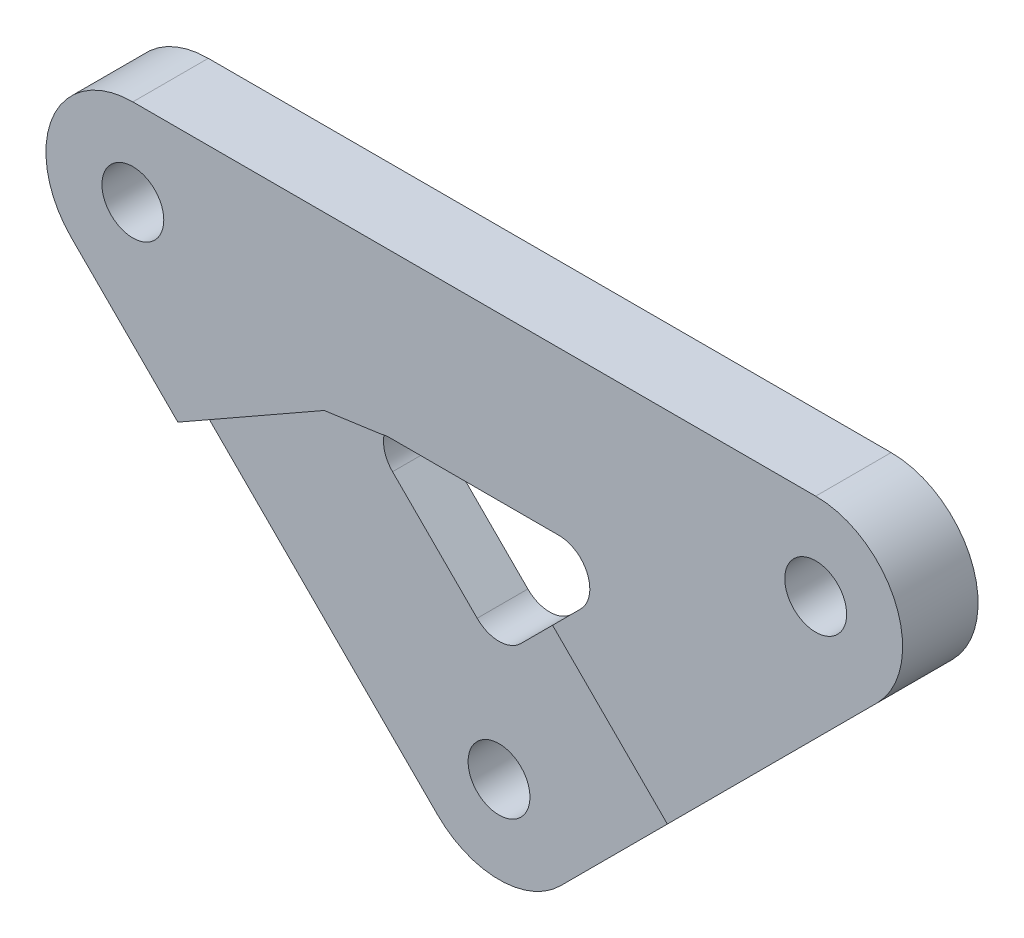
from build123d import *

# Parameters (mm, degrees)
SCHIZZO1_R                   = 2.05
ESTRUSIONE_ESTRUSIONE1_DEPTH = 5
CUT_EXTRUDE2_DEPTH           = 1.64


with BuildPart() as part:
    # Schizzo1 → Estrusione-Estrusione1 (new body)
    with BuildSketch(Plane.XY):
        with BuildLine():
            Line((22.627416998, 28.387976608), (-22.627416998, 28.387976608))
            ThreePointArc((-22.627416998, 28.387976608), (-27.949480117, 24.831887722), (-26.700747761, 18.554086235))
            Line((-26.700747761, 18.554086235), (-4.073330763, -4.073330763))
            ThreePointArc((-4.073330763, -4.073330763), (0, -5.76055961), (4.073330763, -4.073330763))
            Line((4.073330763, -4.073330763), (26.700747761, 18.554086235))
            ThreePointArc((26.700747761, 18.554086235), (27.949480117, 24.831887722), (22.627416998, 28.387976608))
        make_face()
        Circle(SCHIZZO1_R, mode=Mode.SUBTRACT)
        with Locations((22.627416998, 22.627416998)):
            Circle(SCHIZZO1_R, mode=Mode.SUBTRACT)
        with Locations((-22.627416998, 22.627416998)):
            Circle(SCHIZZO1_R, mode=Mode.SUBTRACT)
        with BuildLine():
            Line((5.607211383, 17.627416998), (-5.607211383, 17.627416998))
            ThreePointArc((-5.607211383, 17.627416998), (-7.501164425, 16.361918034), (-7.056780285, 14.127848097))
            Line((-7.056780285, 14.127848097), (-1.449568901, 8.520636713))
            ThreePointArc((-1.449568901, 8.520636713), (0, 7.920205615), (1.449568901, 8.520636713))
            Line((1.449568901, 8.520636713), (7.056780285, 14.127848097))
            ThreePointArc((7.056780285, 14.127848097), (7.501164425, 16.361918034), (5.607211383, 17.627416998))
        make_face(mode=Mode.SUBTRACT)
    extrude(amount=ESTRUSIONE_ESTRUSIONE1_DEPTH)

    # Sketch2 → Cut-Extrude2 (cut)
    with BuildSketch(Plane.XY.offset(5)):
        Polygon((12.797266468, 4.650604941), (0, -8.146661527), (-19.643815137, 11.49715361), (-9.946322881, 17.017390693), (-5.607211383, 17.627416998), (-1.449568901, 8.520636713), (1.449568901, 8.520636713), (5.188401798, 12.25946961), align=None)
    extrude(amount=-CUT_EXTRUDE2_DEPTH, mode=Mode.SUBTRACT)


solid = part.part
